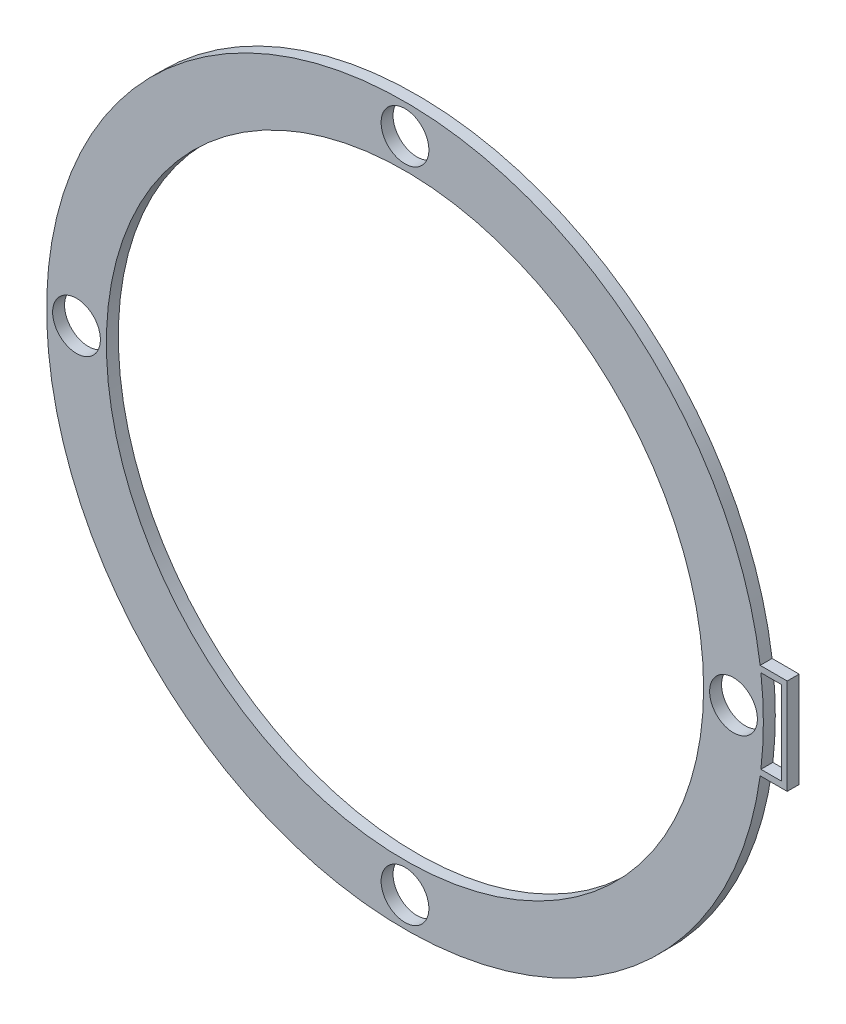
from build123d import *

# Parameters (mm, degrees)
CROQUIS1_R              = 4
CROQUIS1_R_2            = 50
SALIENTE_EXTRUIR1_DEPTH = 2
ESCALA1_SCALE           = 0.5


with BuildPart() as part:
    # Croquis1 → Saliente-Extruir1 (new body)
    with BuildSketch(Plane.XY):
        with BuildLine():
            Line((63.995308988, 8.006149239), (59.46344738, 8.006149239))
            ThreePointArc((59.46344738, 8.006149239), (-60, 0), (59.46344738, -8.006149239))
            Line((59.46344738, -8.006149239), (63.995308988, -8.006149239))
            Line((63.995308988, -8.006149239), (63.995308988, 8.006149239))
        make_face()
        with BuildLine():
            Line((63, -7), (59.590267662, -7))
            ThreePointArc((59.590267662, -7), (60, 0), (59.590267662, 7))
            Line((59.590267662, 7), (63, 7))
            Line((63, 7), (63, -7))
        make_face(mode=Mode.SUBTRACT)
        with Locations((0, 55)):
            Circle(CROQUIS1_R, mode=Mode.SUBTRACT)
        with Locations((55, 0)):
            Circle(CROQUIS1_R, mode=Mode.SUBTRACT)
        with Locations((0, -55)):
            Circle(CROQUIS1_R, mode=Mode.SUBTRACT)
        with Locations((-55, 0)):
            Circle(CROQUIS1_R, mode=Mode.SUBTRACT)
        Circle(CROQUIS1_R_2, mode=Mode.SUBTRACT)
    extrude(amount=SALIENTE_EXTRUIR1_DEPTH)


with BuildPart() as part_1:
    # Escala1: scaled about (0.43933496, 0, 1)
    add(part.part.scale(ESCALA1_SCALE).moved(Location((0.21966748, 0, 0.5))))


solid = part_1.part
